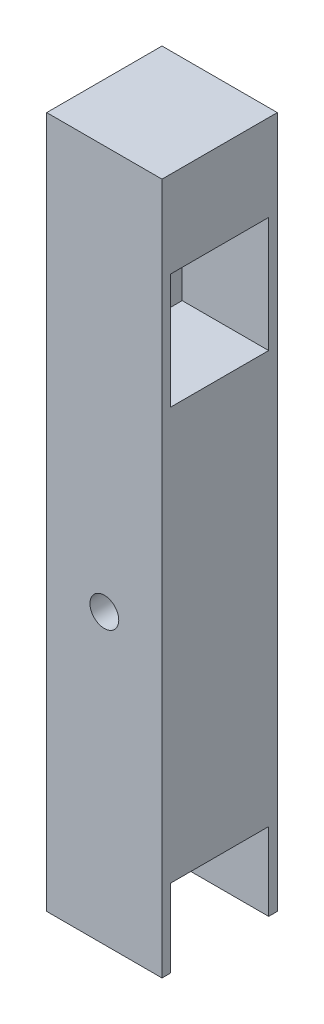
from build123d import *

# Parameters (mm, degrees)
SKETCH1_W           = 25.4
SKETCH1_H           = 152.4
SKETCH1_R           = 3.175
BOSS_EXTRUDE1_DEPTH = 25.4
SKETCH3_R           = 6.35
CUT_EXTRUDE5_DEPTH  = 26.4
SKETCH5_W           = 21.59
SKETCH5_H           = 21.59
SKETCH5_H_2         = 25.4
CUT_EXTRUDE6_DEPTH  = 19.05


with BuildPart() as part:
    # Sketch1 → Boss-Extrude1 (new body)
    with BuildSketch(Plane.XY):
        with Locations((12.7, 76.2)):
            Rectangle(SKETCH1_W, SKETCH1_H)
        with Locations((12.7, 63.5)):
            Circle(SKETCH1_R, mode=Mode.SUBTRACT)
    extrude(amount=BOSS_EXTRUDE1_DEPTH)

    # Sketch3 → Cut-Extrude5 (cut, through all)
    with BuildSketch(Plane(origin=(25.4, 0, 0), x_dir=(0, 0, -1), z_dir=(1, 0, 0))):
        with Locations((-12.7, 120.65254)):
            Circle(SKETCH3_R)
        with Locations((-12.7, 6.35254)):
            Circle(SKETCH3_R)
    extrude(amount=-CUT_EXTRUDE5_DEPTH, mode=Mode.SUBTRACT)

    # Sketch5 → Cut-Extrude6 (cut)
    with BuildSketch(Plane(origin=(25.4, 0, 0), x_dir=(0, 0, -1), z_dir=(1, 0, 0))):
        with Locations((-12.7, 6.35254)):
            Rectangle(SKETCH5_W, SKETCH5_H)
        with Locations((-12.7, 120.65254)):
            Rectangle(SKETCH5_W, SKETCH5_H_2)
    extrude(amount=-CUT_EXTRUDE6_DEPTH, mode=Mode.SUBTRACT)


solid = part.part
